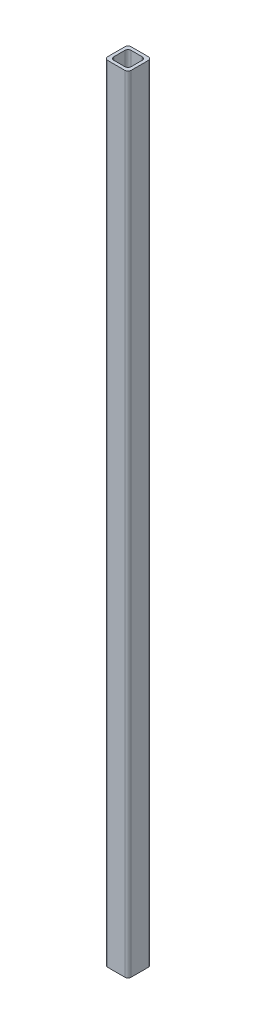
from build123d import *

# Parameters (mm, degrees)
BOSS_EXTRUDE1_DEPTH = 1000


with BuildPart() as part:
    # Sketch1 → Boss-Extrude1 (new body)
    with BuildSketch(Plane(origin=(0, 0, 0), x_dir=(1, 0, 0), z_dir=(0, 1, 0))):
        with BuildLine():
            Line((11, 15), (-11, 15))
            ThreePointArc((-11, 15), (-13.828427125, 13.828427125), (-15, 11))
            Line((-15, 11), (-15, -11))
            ThreePointArc((-15, -11), (-13.828427125, -13.828427125), (-11, -15))
            Line((-11, -15), (11, -15))
            ThreePointArc((11, -15), (13.828427125, -13.828427125), (15, -11))
            Line((15, -11), (15, 11))
            ThreePointArc((15, 11), (13.828427125, 13.828427125), (11, 15))
        make_face()
        with BuildLine():
            Line((7, 11), (-7, 11))
            ThreePointArc((-7, 11), (-9.828427125, 9.828427125), (-11, 7))
            Line((-11, 7), (-11, -7))
            ThreePointArc((-11, -7), (-9.828427125, -9.828427125), (-7, -11))
            Line((-7, -11), (7, -11))
            ThreePointArc((7, -11), (9.828427125, -9.828427125), (11, -7))
            Line((11, -7), (11, 7))
            ThreePointArc((11, 7), (9.828427125, 9.828427125), (7, 11))
        make_face(mode=Mode.SUBTRACT)
    extrude(amount=BOSS_EXTRUDE1_DEPTH)


solid = part.part
